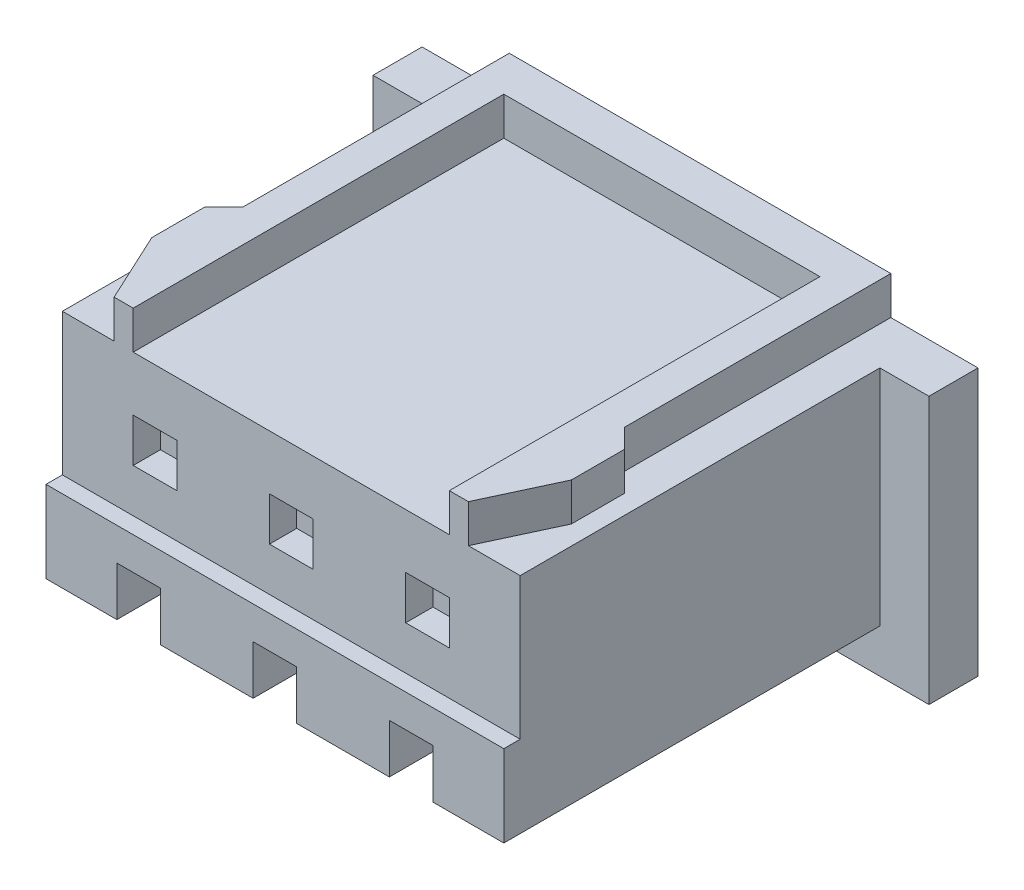
from build123d import *

# Parameters (mm, degrees)
ESQUISSE1_W             = 10.2
ESQUISSE1_H             = 5.6
BOSS_EXTRU_1_DEPTH      = 7.8
ESQUISSE2_W             = 10.2
ESQUISSE2_H             = 3.3
ENL_V_MAT_EXTRU_1_DEPTH = 0.3
ESQUISSE4_W             = 0.9
ESQUISSE4_H             = 3.3
ENL_V_MAT_EXTRU_2_DEPTH = 6.9
ESQUISSE5_W             = 5.8
ESQUISSE5_H             = 6.8
ENL_V_MAT_EXTRU_3_DEPTH = 0.7
ESQUISSE6_W             = 0.8
ESQUISSE6_H             = 0.9
ENL_V_MAT_EXTRU_4_DEPTH = 0.8
ESQUISSE7_W             = 0.8
ESQUISSE7_H             = 0.8
ENL_V_MAT_EXTRU_5_DEPTH = 0.5
ENL_V_MAT_EXTRU_6_DEPTH = 7
ENL_V_MAT_EXTRU_7_DEPTH = 0.8
ESQUISSE10_R            = 0.6
ENL_V_MAT_EXTRU_8_DEPTH = 0.5
ESQUISSE11_W            = 0.8
ESQUISSE11_H            = 0.3
ENL_V_MAT_EXTRU_9_DEPTH = 2.2


with BuildPart() as part:
    # Esquisse1 → Boss.-Extru.1 (new body)
    with BuildSketch(Plane.XY):
        Rectangle(ESQUISSE1_W, ESQUISSE1_H)
    extrude(amount=-BOSS_EXTRU_1_DEPTH)

    # Esquisse2 → Enlèv. mat.-Extru.1 (cut)
    with BuildSketch(Plane.XY):
        with Locations((0, 1.15)):
            Rectangle(ESQUISSE2_W, ESQUISSE2_H)
    extrude(amount=-ENL_V_MAT_EXTRU_1_DEPTH, mode=Mode.SUBTRACT)

    # Esquisse4 → Enlèv. mat.-Extru.2 (cut)
    with BuildSketch(Plane.XY):
        with Locations((-4.65, 1.15)):
            Rectangle(ESQUISSE4_W, ESQUISSE4_H)
        Polygon((5.1, -2.8), (5.1, -0.5), (4.2, -0.5), (4.2, -2), (-4.2, -2), (-4.2, -0.5), (-5.1, -0.5), (-5.1, -2.8), align=None)
        with Locations((4.65, 1.15)):
            Rectangle(ESQUISSE4_W, ESQUISSE4_H)
    extrude(amount=-ENL_V_MAT_EXTRU_2_DEPTH, mode=Mode.SUBTRACT)

    # Esquisse5 → Enlèv. mat.-Extru.3 (cut)
    with BuildSketch(Plane(origin=(0, 2.8, 0), x_dir=(1, 0, 0), z_dir=(0, 1, 0))):
        Polygon((-3.5, 2.91), (-3.5, 7.8), (-5.1, 7.8), (-5.1, 6.9), (-4.2, 6.9), (-4.2, 0.3), (-3.25, 0.3), (-3.85, 1.59), (-3.85, 2.56), align=None)
        Polygon((5.1, 7.8), (3.5, 7.8), (3.5, 2.91), (3.85, 2.56), (3.85, 1.59), (3.25, 0.3), (4.2, 0.3), (4.2, 6.9), (5.1, 6.9), align=None)
        with Locations((0, 3.7)):
            Rectangle(ESQUISSE5_W, ESQUISSE5_H)
    extrude(amount=-ENL_V_MAT_EXTRU_3_DEPTH, mode=Mode.SUBTRACT)

    # Esquisse6 → Enlèv. mat.-Extru.4 (cut)
    with BuildSketch(Plane.XY):
        with Locations((-2.5, -1.55)):
            Rectangle(ESQUISSE6_W, ESQUISSE6_H)
        with Locations((0, -1.55)):
            Rectangle(ESQUISSE6_W, ESQUISSE6_H)
        with Locations((2.5, -1.55)):
            Rectangle(ESQUISSE6_W, ESQUISSE6_H)
    extrude(amount=-ENL_V_MAT_EXTRU_4_DEPTH, mode=Mode.SUBTRACT)

    # Esquisse7 → Enlèv. mat.-Extru.5 (cut)
    with BuildSketch(Plane.XY.offset(-0.3)):
        with Locations((-2.5, 0.7)):
            Rectangle(ESQUISSE7_W, ESQUISSE7_H)
        with Locations((0, 0.7)):
            Rectangle(ESQUISSE7_W, ESQUISSE7_H)
        with Locations((2.5, 0.7)):
            Rectangle(ESQUISSE7_W, ESQUISSE7_H)
    extrude(amount=-ENL_V_MAT_EXTRU_5_DEPTH, mode=Mode.SUBTRACT)

    # Esquisse8 → Enlèv. mat.-Extru.6 (cut)
    with BuildSketch(Plane(origin=(0, 0, -7.8), x_dir=(-1, 0, 0), z_dir=(0, 0, -1))):
        Polygon((0.4, -1.5), (0.8, -1.5), (0.8, 1.5), (-0.8, 1.5), (-0.8, -1.5), (-0.4, -1.5), (-0.4, -1.7), (0.4, -1.7), align=None)
        with BuildLine():
            ThreePointArc((-0.7, 0.95), (-0.35, 1.3), (0, 0.95))
            ThreePointArc((0, 0.95), (0.35, 1.3), (0.7, 0.95))
            Line((0.7, 0.95), (0.7, -1.45))
            Line((0.7, -1.45), (-0.7, -1.45))
            Line((-0.7, -1.45), (-0.7, 0.95))
        make_face(mode=Mode.SUBTRACT)
        Polygon((-2.1, -1.5), (-1.7, -1.5), (-1.7, 1.5), (-3.3, 1.5), (-3.3, -1.5), (-2.9, -1.5), (-2.9, -1.7), (-2.1, -1.7), align=None)
        with BuildLine():
            ThreePointArc((-3.2, 0.95), (-2.85, 1.3), (-2.5, 0.95))
            ThreePointArc((-2.5, 0.95), (-2.15, 1.3), (-1.8, 0.95))
            Line((-1.8, 0.95), (-1.8, -1.45))
            Line((-1.8, -1.45), (-3.2, -1.45))
            Line((-3.2, -1.45), (-3.2, 0.95))
        make_face(mode=Mode.SUBTRACT)
        Polygon((2.9, -1.5), (3.3, -1.5), (3.3, 1.5), (1.7, 1.5), (1.7, -1.5), (2.1, -1.5), (2.1, -1.7), (2.9, -1.7), align=None)
        with BuildLine():
            ThreePointArc((1.8, 0.95), (2.15, 1.3), (2.5, 0.95))
            ThreePointArc((2.5, 0.95), (2.85, 1.3), (3.2, 0.95))
            Line((3.2, 0.95), (3.2, -1.45))
            Line((3.2, -1.45), (1.8, -1.45))
            Line((1.8, -1.45), (1.8, 0.95))
        make_face(mode=Mode.SUBTRACT)
    extrude(amount=-ENL_V_MAT_EXTRU_6_DEPTH, mode=Mode.SUBTRACT)

    # Esquisse9 → Enlèv. mat.-Extru.7 (cut)
    with BuildSketch(Plane(origin=(0, 0, -7.8), x_dir=(-1, 0, 0), z_dir=(0, 0, -1))):
        with BuildLine():
            Line((-0.7, 0.95), (-0.7, -1.45))
            Line((-0.7, -1.45), (0.7, -1.45))
            Line((0.7, -1.45), (0.7, 0.95))
            ThreePointArc((0.7, 0.95), (0.35, 1.3), (0, 0.95))
            ThreePointArc((0, 0.95), (-0.35, 1.3), (-0.7, 0.95))
        make_face()
        with BuildLine():
            Line((-3.2, 0.95), (-3.2, -1.45))
            Line((-3.2, -1.45), (-1.8, -1.45))
            Line((-1.8, -1.45), (-1.8, 0.95))
            ThreePointArc((-1.8, 0.95), (-2.15, 1.3), (-2.5, 0.95))
            ThreePointArc((-2.5, 0.95), (-2.85, 1.3), (-3.2, 0.95))
        make_face()
        with BuildLine():
            Line((1.8, 0.95), (1.8, -1.45))
            Line((1.8, -1.45), (3.2, -1.45))
            Line((3.2, -1.45), (3.2, 0.95))
            ThreePointArc((3.2, 0.95), (2.85, 1.3), (2.5, 0.95))
            ThreePointArc((2.5, 0.95), (2.15, 1.3), (1.8, 0.95))
        make_face()
    extrude(amount=-ENL_V_MAT_EXTRU_7_DEPTH, mode=Mode.SUBTRACT)

    # Esquisse10 → Enlèv. mat.-Extru.8 (cut)
    with BuildSketch(Plane(origin=(0, 0, -7), x_dir=(-1, 0, 0), z_dir=(0, 0, -1))):
        Circle(ESQUISSE10_R)
        with Locations((-2.5, 0)):
            Circle(ESQUISSE10_R)
        with Locations((2.5, 0)):
            Circle(ESQUISSE10_R)
    extrude(amount=-ENL_V_MAT_EXTRU_8_DEPTH, mode=Mode.SUBTRACT)

    # Esquisse11 → Enlèv. mat.-Extru.9 (cut)
    with BuildSketch(Plane.XY.offset(-0.8)):
        with Locations((-2.5, -1.85)):
            Rectangle(ESQUISSE11_W, ESQUISSE11_H)
        with Locations((0, -1.85)):
            Rectangle(ESQUISSE11_W, ESQUISSE11_H)
        with Locations((2.5, -1.85)):
            Rectangle(ESQUISSE11_W, ESQUISSE11_H)
    extrude(amount=-ENL_V_MAT_EXTRU_9_DEPTH, mode=Mode.SUBTRACT)


solid = part.part
